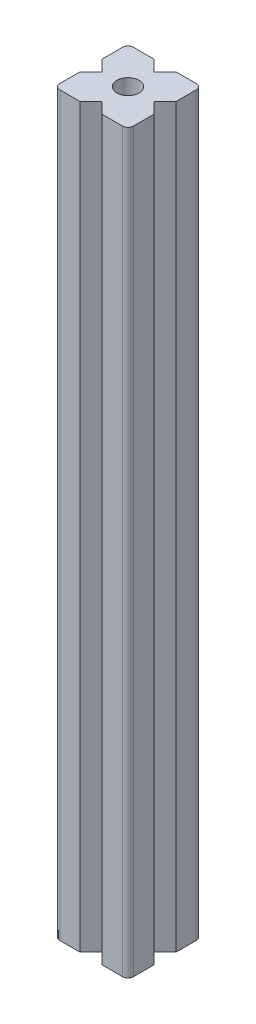
from build123d import *

# Parameters (mm, degrees)
SKIZZE1_W                       = 20
SKIZZE1_H                       = 20
AUFSATZ_LINEAR_AUSTRAGEN1_DEPTH = 200
SCHNITT_LINEAR_AUSTRAGEN1_DEPTH = 201
SKIZZE3_R                       = 3
SCHNITT_LINEAR_AUSTRAGEN2_DEPTH = 201
FILLET1_R                       = 1.5


with BuildPart() as part:
    # Skizze1 → Aufsatz-Linear austragen1 (new body)
    with BuildSketch(Plane(origin=(0, 0, 0), x_dir=(1, 0, 0), z_dir=(0, 1, 0))):
        with Locations((10, 10)):
            Rectangle(SKIZZE1_W, SKIZZE1_H)
    extrude(amount=AUFSATZ_LINEAR_AUSTRAGEN1_DEPTH)

    # Skizze2 → Schnitt-Linear austragen1 (cut, through all)
    with BuildSketch(Plane(origin=(0, 200, 0), x_dir=(1, 0, 0), z_dir=(0, 1, 0))):
        Polygon((7, 20), (10, 17), (13, 20), align=None)
        Polygon((20, 13), (17, 10), (20, 7), align=None)
        Polygon((0, 7), (0, 13), (3, 10), align=None)
        Polygon((7, 0), (13, 0), (10, 3), align=None)
    extrude(amount=-SCHNITT_LINEAR_AUSTRAGEN1_DEPTH, mode=Mode.SUBTRACT)

    # Skizze3 → Schnitt-Linear austragen2 (cut, through all)
    with BuildSketch(Plane(origin=(0, 200, 0), x_dir=(1, 0, 0), z_dir=(0, 1, 0))):
        with Locations((10, 10)):
            Circle(SKIZZE3_R)
    extrude(amount=-SCHNITT_LINEAR_AUSTRAGEN2_DEPTH, mode=Mode.SUBTRACT)

    # Fillet1
    fillet1_edges = [part.edges().sort_by_distance(p)[0] for p in [
        (0, 100, -20),
        (20, 100, -20),
        (20, 100, 0),
        (0, 100, 0),
    ]]
    fillet(fillet1_edges, radius=FILLET1_R)


solid = part.part
